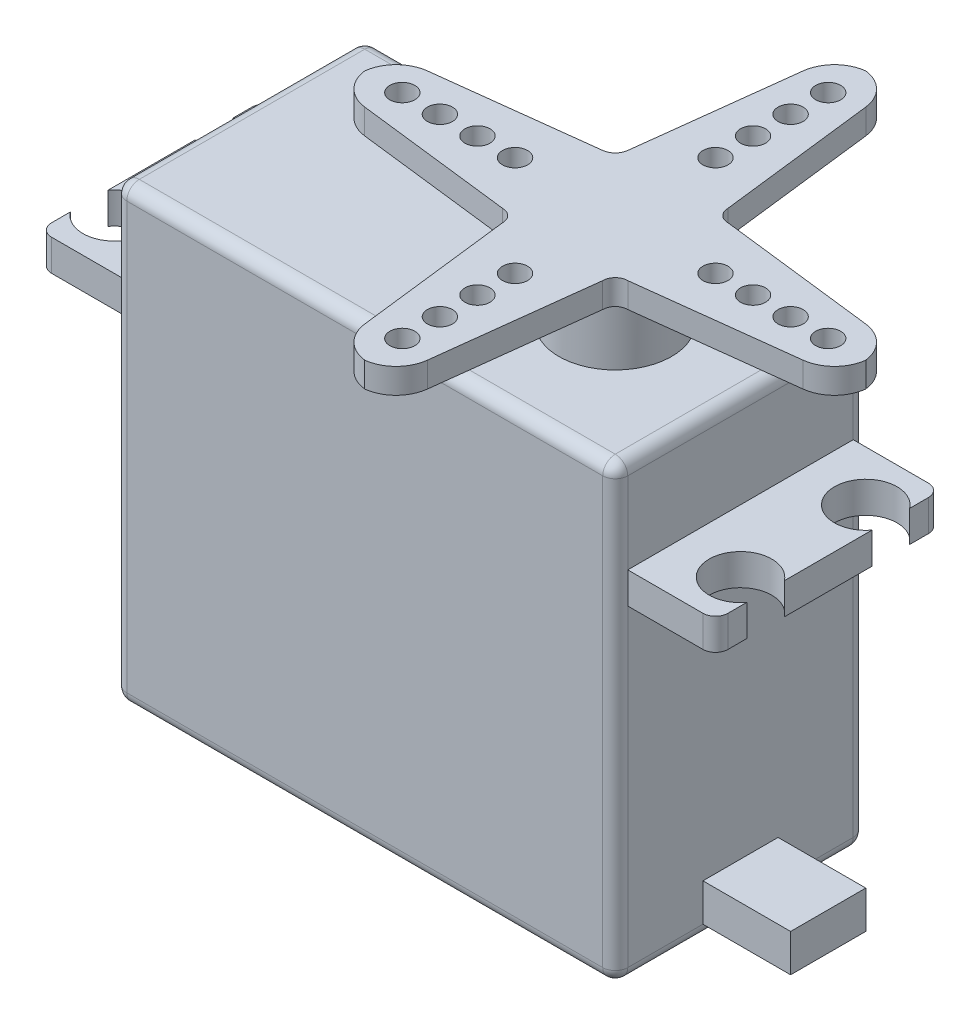
from build123d import *

# Parameters (mm, degrees)
SKETCH2_W           = 40
SKETCH2_H           = 20
BOSS_EXTRUDE1_DEPTH = 36
FILLET1_R           = 1
SKETCH4_W           = 18
SKETCH4_H           = 2.5
BOSS_EXTRUDE2_DEPTH = 7
CUT_EXTRUDE1_REACH  = 30.5
SKETCH5_R           = 2.5
FILLET2_R           = 1
SKETCH7_W           = 18
SKETCH7_H           = 2.5
BOSS_EXTRUDE3_DEPTH = 7
FILLET3_R           = 1
CUT_EXTRUDE2_REACH  = 30.5
SKETCH8_R           = 2.5
SKETCH9_R           = 4.5
BOSS_EXTRUDE4_DEPTH = 5.5
BOSS_EXTRUDE5_DEPTH = 2
CUT_EXTRUDE3_REACH  = 45.5
SKETCH11_R          = 1
SKETCH12_W          = 6
SKETCH12_H          = 3
BOSS_EXTRUDE6_DEPTH = 7


with BuildPart() as part:
    # Sketch2 → Boss-Extrude1 (new body)
    with BuildSketch(Plane(origin=(0, 0, 0), x_dir=(1, 0, 0), z_dir=(0, 1, 0))):
        with Locations((20, 10)):
            Rectangle(SKETCH2_W, SKETCH2_H)
    extrude(amount=BOSS_EXTRUDE1_DEPTH)

    # Fillet1
    fillet1_edges = [part.edges().sort_by_distance(p)[0] for p in [
        (40, 36, -10),
        (20, 36, -20),
        (0, 36, -10),
        (20, 0, -20),
        (40, 0, -10),
        (20, 0, 0),
        (0, 0, -10),
        (20, 36, 0),
        (0, 18, -20),
        (40, 18, -20),
        (40, 18, 0),
        (0, 18, 0),
    ]]
    fillet(fillet1_edges, radius=FILLET1_R)

    # Sketch4 → Boss-Extrude2 (add)
    with BuildSketch(Plane(origin=(40, 0, 0), x_dir=(0, 0, -1), z_dir=(1, 0, 0))):
        with Locations((10, 27.25)):
            Rectangle(SKETCH4_W, SKETCH4_H)
    extrude(amount=BOSS_EXTRUDE2_DEPTH)

    # Sketch5 → Cut-Extrude1 (cut, up to next)
    with BuildSketch(Plane(origin=(0, 28.5, 0), x_dir=(1, 0, 0), z_dir=(0, 1, 0)), mode=Mode.PRIVATE) as cut_extrude1_sk1:
        with Locations((45, 5)):
            Circle(SKETCH5_R)
    cut_extrude1_tool1 = extrude(cut_extrude1_sk1.sketch, amount=-CUT_EXTRUDE1_REACH, mode=Mode.PRIVATE) & part.part
    add(cut_extrude1_tool1.solids().sort_by_distance((45, 28.5, -5))[0], mode=Mode.SUBTRACT)
    # Sketch5 → Cut-Extrude1 (cut, up to next)
    with BuildSketch(Plane(origin=(0, 28.5, 0), x_dir=(1, 0, 0), z_dir=(0, 1, 0)), mode=Mode.PRIVATE) as cut_extrude1_sk2:
        with Locations((45, 15)):
            Circle(SKETCH5_R)
    cut_extrude1_tool2 = extrude(cut_extrude1_sk2.sketch, amount=-CUT_EXTRUDE1_REACH, mode=Mode.PRIVATE) & part.part
    add(cut_extrude1_tool2.solids().sort_by_distance((45, 28.5, -15))[0], mode=Mode.SUBTRACT)

    # Fillet2
    fillet2_edges = [part.edges().sort_by_distance(p)[0] for p in [
        (47, 27.25, -19),
        (47, 27.25, -1),
    ]]
    fillet(fillet2_edges, radius=FILLET2_R)

    # Sketch7 → Boss-Extrude3 (add)
    with BuildSketch(Plane.ZY):
        with Locations((-10, 27.25)):
            Rectangle(SKETCH7_W, SKETCH7_H)
    extrude(amount=BOSS_EXTRUDE3_DEPTH)

    # Fillet3
    fillet3_edges = [part.edges().sort_by_distance(p)[0] for p in [
        (-7, 27.25, -19),
        (-7, 27.25, -1),
    ]]
    fillet(fillet3_edges, radius=FILLET3_R)

    # Sketch8 → Cut-Extrude2 (cut, up to next)
    with BuildSketch(Plane(origin=(0, 28.5, 0), x_dir=(1, 0, 0), z_dir=(0, 1, 0)), mode=Mode.PRIVATE) as cut_extrude2_sk1:
        with Locations((-5, 15)):
            Circle(SKETCH8_R)
    cut_extrude2_tool1 = extrude(cut_extrude2_sk1.sketch, amount=-CUT_EXTRUDE2_REACH, mode=Mode.PRIVATE) & part.part
    add(cut_extrude2_tool1.solids().sort_by_distance((-5, 28.5, -15))[0], mode=Mode.SUBTRACT)
    # Sketch8 → Cut-Extrude2 (cut, up to next)
    with BuildSketch(Plane(origin=(0, 28.5, 0), x_dir=(1, 0, 0), z_dir=(0, 1, 0)), mode=Mode.PRIVATE) as cut_extrude2_sk2:
        with Locations((-5, 5)):
            Circle(SKETCH8_R)
    cut_extrude2_tool2 = extrude(cut_extrude2_sk2.sketch, amount=-CUT_EXTRUDE2_REACH, mode=Mode.PRIVATE) & part.part
    add(cut_extrude2_tool2.solids().sort_by_distance((-5, 28.5, -5))[0], mode=Mode.SUBTRACT)

    # Sketch9 → Boss-Extrude4 (add)
    with BuildSketch(Plane(origin=(0, 36, 0), x_dir=(1, 0, 0), z_dir=(0, 1, 0))):
        with Locations((30, 10)):
            Circle(SKETCH9_R)
    extrude(amount=BOSS_EXTRUDE4_DEPTH)

    # Sketch10 → Boss-Extrude5 (add)
    with BuildSketch(Plane(origin=(0, 41.5, 0), x_dir=(1, 0, 0), z_dir=(0, 1, 0))):
        with BuildLine():
            Line((27.5, 27.5), (26, 15))
            ThreePointArc((26, 15), (25.672931537, 14.327068463), (25, 14))
            Line((25, 14), (12.5, 12.5))
            ThreePointArc((12.5, 12.5), (10.817671157, 11.682328843), (10, 10))
            ThreePointArc((10, 10), (10.817671157, 8.317671157), (12.5, 7.5))
            Line((12.5, 7.5), (25, 6))
            ThreePointArc((25, 6), (25.707106781, 5.707106781), (26, 5))
            Line((26, 5), (27.5, -7.5))
            ThreePointArc((27.5, -7.5), (28.317671157, -9.182328843), (30, -10))
            ThreePointArc((30, -10), (31.682328843, -9.182328843), (32.5, -7.5))
            Line((32.5, -7.5), (34, 5))
            ThreePointArc((34, 5), (34.292893219, 5.707106781), (35, 6))
            Line((35, 6), (47.5, 7.5))
            ThreePointArc((47.5, 7.5), (49.182328843, 8.317671157), (50, 10))
            ThreePointArc((50, 10), (49.182328843, 11.682328843), (47.5, 12.5))
            Line((47.5, 12.5), (35, 14))
            ThreePointArc((35, 14), (34.292893219, 14.292893219), (34, 15))
            Line((34, 15), (32.5, 27.5))
            ThreePointArc((32.5, 27.5), (31.682328843, 29.182328843), (30, 30))
            ThreePointArc((30, 30), (28.317671157, 29.182328843), (27.5, 27.5))
        make_face()
    extrude(amount=BOSS_EXTRUDE5_DEPTH)

    # Sketch11 → Cut-Extrude3 (cut, up to next)
    with BuildSketch(Plane(origin=(0, 43.5, 0), x_dir=(1, 0, 0), z_dir=(0, 1, 0)), mode=Mode.PRIVATE) as cut_extrude3_sk1:
        with Locations((30, 27)):
            Circle(SKETCH11_R)
    cut_extrude3_tool1 = extrude(cut_extrude3_sk1.sketch, amount=-CUT_EXTRUDE3_REACH, mode=Mode.PRIVATE) & part.part
    add(cut_extrude3_tool1.solids().sort_by_distance((30, 43.5, -27))[0], mode=Mode.SUBTRACT)
    # Sketch11 → Cut-Extrude3 (cut, up to next)
    with BuildSketch(Plane(origin=(0, 43.5, 0), x_dir=(1, 0, 0), z_dir=(0, 1, 0)), mode=Mode.PRIVATE) as cut_extrude3_sk2:
        with Locations((30, 24)):
            Circle(SKETCH11_R)
    cut_extrude3_tool2 = extrude(cut_extrude3_sk2.sketch, amount=-CUT_EXTRUDE3_REACH, mode=Mode.PRIVATE) & part.part
    add(cut_extrude3_tool2.solids().sort_by_distance((30, 43.5, -24))[0], mode=Mode.SUBTRACT)
    # Sketch11 → Cut-Extrude3 (cut, up to next)
    with BuildSketch(Plane(origin=(0, 43.5, 0), x_dir=(1, 0, 0), z_dir=(0, 1, 0)), mode=Mode.PRIVATE) as cut_extrude3_sk3:
        with Locations((30, 21)):
            Circle(SKETCH11_R)
    cut_extrude3_tool3 = extrude(cut_extrude3_sk3.sketch, amount=-CUT_EXTRUDE3_REACH, mode=Mode.PRIVATE) & part.part
    add(cut_extrude3_tool3.solids().sort_by_distance((30, 43.5, -21))[0], mode=Mode.SUBTRACT)
    # Sketch11 → Cut-Extrude3 (cut, up to next)
    with BuildSketch(Plane(origin=(0, 43.5, 0), x_dir=(1, 0, 0), z_dir=(0, 1, 0)), mode=Mode.PRIVATE) as cut_extrude3_sk4:
        with Locations((30, 18)):
            Circle(SKETCH11_R)
    cut_extrude3_tool4 = extrude(cut_extrude3_sk4.sketch, amount=-CUT_EXTRUDE3_REACH, mode=Mode.PRIVATE) & part.part
    add(cut_extrude3_tool4.solids().sort_by_distance((30, 43.5, -18))[0], mode=Mode.SUBTRACT)
    # Sketch11 → Cut-Extrude3 (cut, up to next)
    with BuildSketch(Plane(origin=(0, 43.5, 0), x_dir=(1, 0, 0), z_dir=(0, 1, 0)), mode=Mode.PRIVATE) as cut_extrude3_sk5:
        with Locations((47, 10)):
            Circle(SKETCH11_R)
    cut_extrude3_tool5 = extrude(cut_extrude3_sk5.sketch, amount=-CUT_EXTRUDE3_REACH, mode=Mode.PRIVATE) & part.part
    add(cut_extrude3_tool5.solids().sort_by_distance((47, 43.5, -10))[0], mode=Mode.SUBTRACT)
    # Sketch11 → Cut-Extrude3 (cut, up to next)
    with BuildSketch(Plane(origin=(0, 43.5, 0), x_dir=(1, 0, 0), z_dir=(0, 1, 0)), mode=Mode.PRIVATE) as cut_extrude3_sk6:
        with Locations((44, 10)):
            Circle(SKETCH11_R)
    cut_extrude3_tool6 = extrude(cut_extrude3_sk6.sketch, amount=-CUT_EXTRUDE3_REACH, mode=Mode.PRIVATE) & part.part
    add(cut_extrude3_tool6.solids().sort_by_distance((44, 43.5, -10))[0], mode=Mode.SUBTRACT)
    # Sketch11 → Cut-Extrude3 (cut, up to next)
    with BuildSketch(Plane(origin=(0, 43.5, 0), x_dir=(1, 0, 0), z_dir=(0, 1, 0)), mode=Mode.PRIVATE) as cut_extrude3_sk7:
        with Locations((41, 10)):
            Circle(SKETCH11_R)
    cut_extrude3_tool7 = extrude(cut_extrude3_sk7.sketch, amount=-CUT_EXTRUDE3_REACH, mode=Mode.PRIVATE) & part.part
    add(cut_extrude3_tool7.solids().sort_by_distance((41, 43.5, -10))[0], mode=Mode.SUBTRACT)
    # Sketch11 → Cut-Extrude3 (cut, up to next)
    with BuildSketch(Plane(origin=(0, 43.5, 0), x_dir=(1, 0, 0), z_dir=(0, 1, 0)), mode=Mode.PRIVATE) as cut_extrude3_sk8:
        with Locations((38, 10)):
            Circle(SKETCH11_R)
    cut_extrude3_tool8 = extrude(cut_extrude3_sk8.sketch, amount=-CUT_EXTRUDE3_REACH, mode=Mode.PRIVATE) & part.part
    add(cut_extrude3_tool8.solids().sort_by_distance((38, 43.5, -10))[0], mode=Mode.SUBTRACT)
    # Sketch11 → Cut-Extrude3 (cut, up to next)
    with BuildSketch(Plane(origin=(0, 43.5, 0), x_dir=(1, 0, 0), z_dir=(0, 1, 0)), mode=Mode.PRIVATE) as cut_extrude3_sk9:
        with Locations((30, -7)):
            Circle(SKETCH11_R)
    cut_extrude3_tool9 = extrude(cut_extrude3_sk9.sketch, amount=-CUT_EXTRUDE3_REACH, mode=Mode.PRIVATE) & part.part
    add(cut_extrude3_tool9.solids().sort_by_distance((30, 43.5, 7))[0], mode=Mode.SUBTRACT)
    # Sketch11 → Cut-Extrude3 (cut, up to next)
    with BuildSketch(Plane(origin=(0, 43.5, 0), x_dir=(1, 0, 0), z_dir=(0, 1, 0)), mode=Mode.PRIVATE) as cut_extrude3_sk10:
        with Locations((30, -4)):
            Circle(SKETCH11_R)
    cut_extrude3_tool10 = extrude(cut_extrude3_sk10.sketch, amount=-CUT_EXTRUDE3_REACH, mode=Mode.PRIVATE) & part.part
    add(cut_extrude3_tool10.solids().sort_by_distance((30, 43.5, 4))[0], mode=Mode.SUBTRACT)
    # Sketch11 → Cut-Extrude3 (cut, up to next)
    with BuildSketch(Plane(origin=(0, 43.5, 0), x_dir=(1, 0, 0), z_dir=(0, 1, 0)), mode=Mode.PRIVATE) as cut_extrude3_sk11:
        with Locations((30, -1)):
            Circle(SKETCH11_R)
    cut_extrude3_tool11 = extrude(cut_extrude3_sk11.sketch, amount=-CUT_EXTRUDE3_REACH, mode=Mode.PRIVATE) & part.part
    add(cut_extrude3_tool11.solids().sort_by_distance((30, 43.5, 1))[0], mode=Mode.SUBTRACT)
    # Sketch11 → Cut-Extrude3 (cut, up to next)
    with BuildSketch(Plane(origin=(0, 43.5, 0), x_dir=(1, 0, 0), z_dir=(0, 1, 0)), mode=Mode.PRIVATE) as cut_extrude3_sk12:
        with Locations((30, 2)):
            Circle(SKETCH11_R)
    cut_extrude3_tool12 = extrude(cut_extrude3_sk12.sketch, amount=-CUT_EXTRUDE3_REACH, mode=Mode.PRIVATE) & part.part
    add(cut_extrude3_tool12.solids().sort_by_distance((30, 43.5, -2))[0], mode=Mode.SUBTRACT)
    # Sketch11 → Cut-Extrude3 (cut, up to next)
    with BuildSketch(Plane(origin=(0, 43.5, 0), x_dir=(1, 0, 0), z_dir=(0, 1, 0)), mode=Mode.PRIVATE) as cut_extrude3_sk13:
        with Locations((13, 10)):
            Circle(SKETCH11_R)
    cut_extrude3_tool13 = extrude(cut_extrude3_sk13.sketch, amount=-CUT_EXTRUDE3_REACH, mode=Mode.PRIVATE) & part.part
    add(cut_extrude3_tool13.solids().sort_by_distance((13, 43.5, -10))[0], mode=Mode.SUBTRACT)
    # Sketch11 → Cut-Extrude3 (cut, up to next)
    with BuildSketch(Plane(origin=(0, 43.5, 0), x_dir=(1, 0, 0), z_dir=(0, 1, 0)), mode=Mode.PRIVATE) as cut_extrude3_sk14:
        with Locations((16, 10)):
            Circle(SKETCH11_R)
    cut_extrude3_tool14 = extrude(cut_extrude3_sk14.sketch, amount=-CUT_EXTRUDE3_REACH, mode=Mode.PRIVATE) & part.part
    add(cut_extrude3_tool14.solids().sort_by_distance((16, 43.5, -10))[0], mode=Mode.SUBTRACT)
    # Sketch11 → Cut-Extrude3 (cut, up to next)
    with BuildSketch(Plane(origin=(0, 43.5, 0), x_dir=(1, 0, 0), z_dir=(0, 1, 0)), mode=Mode.PRIVATE) as cut_extrude3_sk15:
        with Locations((19, 10)):
            Circle(SKETCH11_R)
    cut_extrude3_tool15 = extrude(cut_extrude3_sk15.sketch, amount=-CUT_EXTRUDE3_REACH, mode=Mode.PRIVATE) & part.part
    add(cut_extrude3_tool15.solids().sort_by_distance((19, 43.5, -10))[0], mode=Mode.SUBTRACT)
    # Sketch11 → Cut-Extrude3 (cut, up to next)
    with BuildSketch(Plane(origin=(0, 43.5, 0), x_dir=(1, 0, 0), z_dir=(0, 1, 0)), mode=Mode.PRIVATE) as cut_extrude3_sk16:
        with Locations((22, 10)):
            Circle(SKETCH11_R)
    cut_extrude3_tool16 = extrude(cut_extrude3_sk16.sketch, amount=-CUT_EXTRUDE3_REACH, mode=Mode.PRIVATE) & part.part
    add(cut_extrude3_tool16.solids().sort_by_distance((22, 43.5, -10))[0], mode=Mode.SUBTRACT)

    # Sketch12 → Boss-Extrude6 (add)
    with BuildSketch(Plane(origin=(40, 0, 0), x_dir=(0, 0, -1), z_dir=(1, 0, 0))):
        with Locations((10, 2.5)):
            Rectangle(SKETCH12_W, SKETCH12_H)
    extrude(amount=BOSS_EXTRUDE6_DEPTH)


solid = part.part
